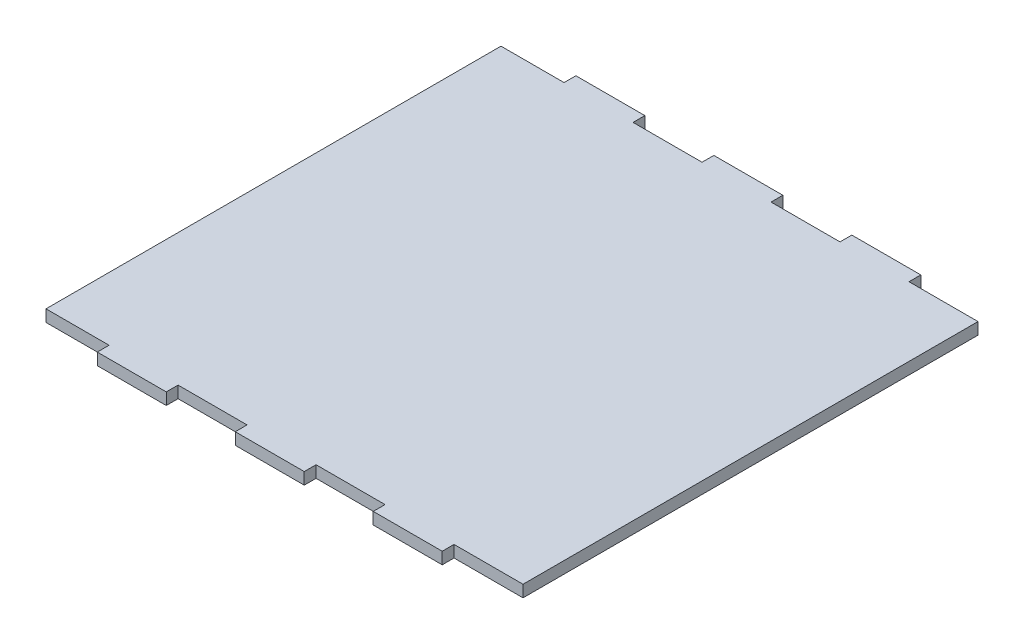
from build123d import *

# Parameters (mm, degrees)
BOSS_EXTRUDE1_DEPTH = 3
SKETCH2_W           = 1.5
SKETCH2_H           = 115.6
CUT_EXTRUDE1_DEPTH  = 4


with BuildPart() as part:
    # Sketch1 → Boss-Extrude1 (new body)
    with BuildSketch(Plane(origin=(0, 0, 0), x_dir=(1, 0, 0), z_dir=(0, 1, 0))):
        Polygon((0, 0), (17.52857143, 0), (17.52857143, -3), (35.05714243, -3), (35.05714243, 0), (52.58571343, 0), (52.58571343, -3), (70.11428443, -3), (70.11428443, 0), (87.64285543, 0), (87.64285543, -3), (105.17142643, -3), (105.17142643, 0), (122.7, 0), (122.7, 115.6), (105.17142643, 115.6), (105.17142643, 118.6), (87.64285543, 118.6), (87.64285543, 115.6), (70.11428443, 115.6), (70.11428443, 118.6), (52.58571343, 118.6), (52.58571343, 115.6), (35.05714243, 115.6), (35.05714243, 118.6), (17.52857143, 118.6), (17.52857143, 115.6), (0, 115.6), align=None)
    extrude(amount=BOSS_EXTRUDE1_DEPTH)

    # Sketch2 → Cut-Extrude1 (cut, through all)
    with BuildSketch(Plane.XZ):
        with Locations((0.75, -57.8)):
            Rectangle(SKETCH2_W, SKETCH2_H)
    extrude(amount=-CUT_EXTRUDE1_DEPTH, mode=Mode.SUBTRACT)


solid = part.part
